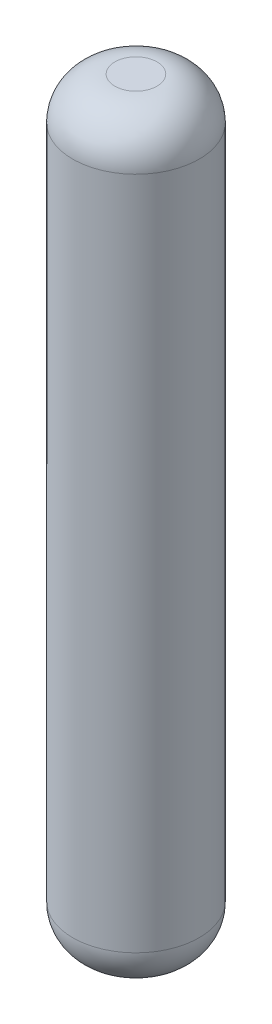
from build123d import *


with BuildPart() as part:
    # Эскиз1 → Повернуть3 (revolve)
    with BuildSketch(Plane.XY):
        with BuildLine():
            Line((-2.026354969, -0.193820225), (-2.026354969, -18.193820225))
            Line((-2.026354969, -18.193820225), (-1.526354969, -18.193820225))
            ThreePointArc((-1.526354969, -18.193820225), (-0.819248188, -17.900927006), (-0.526354969, -17.193820225))
            Line((-0.526354969, -17.193820225), (-0.526354969, -1.193820225))
            ThreePointArc((-0.526354969, -1.193820225), (-0.819248188, -0.486713444), (-1.526354969, -0.193820225))
            Line((-1.526354969, -0.193820225), (-2.026354969, -0.193820225))
        make_face()
    revolve(axis=Axis((-2.026354969, -0.193820225, 0), (0, -1, 0)))


solid = part.part
